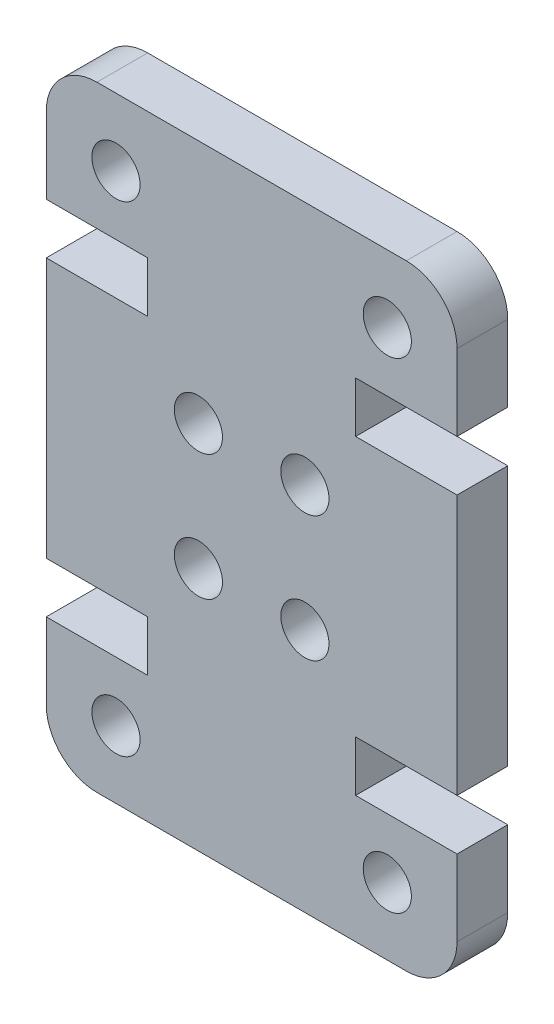
from build123d import *

# Parameters (mm, degrees)
SKETCH1_R           = 0.95
BOSS_EXTRUDE1_DEPTH = 2


with BuildPart() as part:
    # Sketch1 → Boss-Extrude1 (new body)
    with BuildSketch(Plane.XY):
        with BuildLine():
            Line((16.2, 17.26), (16.2, 7))
            Line((16.2, 7), (12.2, 7))
            Line((12.2, 7), (12.2, 5))
            Line((12.2, 5), (16.2, 5))
            Line((16.2, 5), (16.2, 2))
            ThreePointArc((16.2, 2), (15.614213562, 0.585786438), (14.2, 0))
            Line((14.2, 0), (2, 0))
            ThreePointArc((2, 0), (0.585786438, 0.585786438), (0, 2))
            Line((0, 2), (0, 5))
            Line((0, 5), (4, 5))
            Line((4, 5), (4, 7))
            Line((4, 7), (0, 7))
            Line((0, 7), (0, 17.26))
            Line((0, 17.26), (4, 17.26))
            Line((4, 17.26), (4, 19.26))
            Line((4, 19.26), (0, 19.26))
            Line((0, 19.26), (0, 22.26))
            ThreePointArc((0, 22.26), (0.585786438, 23.674213562), (2, 24.26))
            Line((2, 24.26), (14.2, 24.26))
            ThreePointArc((14.2, 24.26), (15.614213562, 23.674213562), (16.2, 22.26))
            Line((16.2, 22.26), (16.2, 19.26))
            Line((16.2, 19.26), (12.2, 19.26))
            Line((12.2, 19.26), (12.2, 17.26))
            Line((12.2, 17.26), (16.2, 17.26))
        make_face()
        with Locations((13.45, 2.653551169)):
            Circle(SKETCH1_R, mode=Mode.SUBTRACT)
        with Locations((10.2, 9.653551169)):
            Circle(SKETCH1_R, mode=Mode.SUBTRACT)
        with Locations((2.75, 21.606448831)):
            Circle(SKETCH1_R, mode=Mode.SUBTRACT)
        with Locations((6, 14.606448831)):
            Circle(SKETCH1_R, mode=Mode.SUBTRACT)
        with Locations((10.2, 14.606448831)):
            Circle(SKETCH1_R, mode=Mode.SUBTRACT)
        with Locations((13.45, 21.606448831)):
            Circle(SKETCH1_R, mode=Mode.SUBTRACT)
        with Locations((6, 9.653551169)):
            Circle(SKETCH1_R, mode=Mode.SUBTRACT)
        with Locations((2.75, 2.653551169)):
            Circle(SKETCH1_R, mode=Mode.SUBTRACT)
    extrude(amount=BOSS_EXTRUDE1_DEPTH)


solid = part.part
